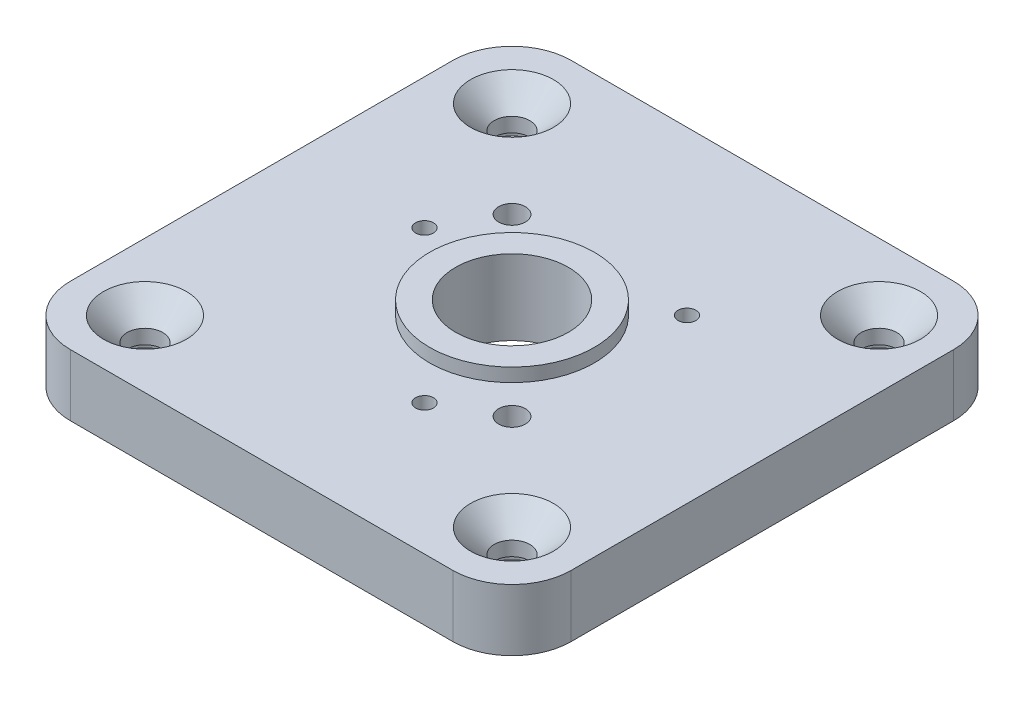
from build123d import *

# Parameters (mm, degrees)
SKETCH1_W           = 42.3
SKETCH1_H           = 42.3
SKETCH1_R           = 1.5
SKETCH1_R_2         = 4.7625
BOSS_EXTRUDE1_DEPTH = 5.21
SKETCH2_R           = 0.75565
SKETCH2_R_2         = 1.1303
CUT_EXTRUDE1_DEPTH  = 6.21
CHAMFER1_SIZE       = 2
SKETCH4_R           = 6.96
SKETCH4_R_2         = 4.7625
BOSS_EXTRUDE2_DEPTH = 1.14
SKETCH5_R           = 4
SKETCH5_R_2         = 1.5
CUT_EXTRUDE2_DEPTH  = 2
FILLET1_R           = 5


with BuildPart() as part:
    # Sketch1 → Boss-Extrude1 (new body)
    with BuildSketch(Plane(origin=(0, 0, 0), x_dir=(1, 0, 0), z_dir=(0, 1, 0))):
        with Locations((21.15, 21.15)):
            Rectangle(SKETCH1_W, SKETCH1_H)
        with Locations((36.65, 36.65)):
            Circle(SKETCH1_R, mode=Mode.SUBTRACT)
        with Locations((5.65, 5.65)):
            Circle(SKETCH1_R, mode=Mode.SUBTRACT)
        with Locations((36.65, 5.65)):
            Circle(SKETCH1_R, mode=Mode.SUBTRACT)
        with Locations((5.65, 36.65)):
            Circle(SKETCH1_R, mode=Mode.SUBTRACT)
        with Locations((21.15, 21.15)):
            Circle(SKETCH1_R_2, mode=Mode.SUBTRACT)
    extrude(amount=BOSS_EXTRUDE1_DEPTH)

    # Sketch2 → Cut-Extrude1 (cut, through all)
    with BuildSketch(Plane(origin=(0, 5.21, 0), x_dir=(1, 0, 0), z_dir=(0, 1, 0))):
        with Locations((11.056075115, 23.854659021)):
            Circle(SKETCH2_R)
        with Locations((28.539265863, 28.539265863)):
            Circle(SKETCH2_R)
        with Locations((23.854659021, 11.056075115)):
            Circle(SKETCH2_R)
        with Locations((28.539265863, 13.760734137)):
            Circle(SKETCH2_R_2)
        with Locations((13.760734137, 28.539265863)):
            Circle(SKETCH2_R_2)
    extrude(amount=-CUT_EXTRUDE1_DEPTH, mode=Mode.SUBTRACT)

    # Chamfer1
    chamfer1_edges = [part.edges().sort_by_distance(p)[0] for p in [
        (35.15, 5.21, -36.65),
        (4.15, 5.21, -5.65),
        (35.15, 5.21, -5.65),
        (4.15, 5.21, -36.65),
    ]]
    chamfer(chamfer1_edges, length=CHAMFER1_SIZE)

    # Sketch4 → Boss-Extrude2 (add)
    with BuildSketch(Plane(origin=(0, 5.21, 0), x_dir=(1, 0, 0), z_dir=(0, 1, 0))):
        with Locations((21.15, 21.15)):
            Circle(SKETCH4_R)
        with Locations((21.15, 21.15)):
            Circle(SKETCH4_R_2, mode=Mode.SUBTRACT)
    extrude(amount=BOSS_EXTRUDE2_DEPTH)

    # Sketch5 → Cut-Extrude2 (cut)
    with BuildSketch(Plane.XZ):
        with Locations((36.65, -36.65)):
            Circle(SKETCH5_R)
        with Locations((36.65, -36.65)):
            Circle(SKETCH5_R_2, mode=Mode.SUBTRACT)
        with Locations((5.65, -36.65)):
            Circle(SKETCH5_R)
        with Locations((5.65, -36.65)):
            Circle(SKETCH5_R_2, mode=Mode.SUBTRACT)
        with Locations((5.65, -5.65)):
            Circle(SKETCH5_R)
        with Locations((5.65, -5.65)):
            Circle(SKETCH5_R_2, mode=Mode.SUBTRACT)
        with Locations((36.65, -5.65)):
            Circle(SKETCH5_R)
        with Locations((36.65, -5.65)):
            Circle(SKETCH5_R_2, mode=Mode.SUBTRACT)
    extrude(amount=-CUT_EXTRUDE2_DEPTH, mode=Mode.SUBTRACT)

    # Fillet1
    fillet1_edges = [part.edges().sort_by_distance(p)[0] for p in [
        (0, 2.605, -42.3),
        (42.3, 2.605, -42.3),
        (42.3, 2.605, 0),
        (0, 2.605, 0),
    ]]
    fillet(fillet1_edges, radius=FILLET1_R)


solid = part.part
